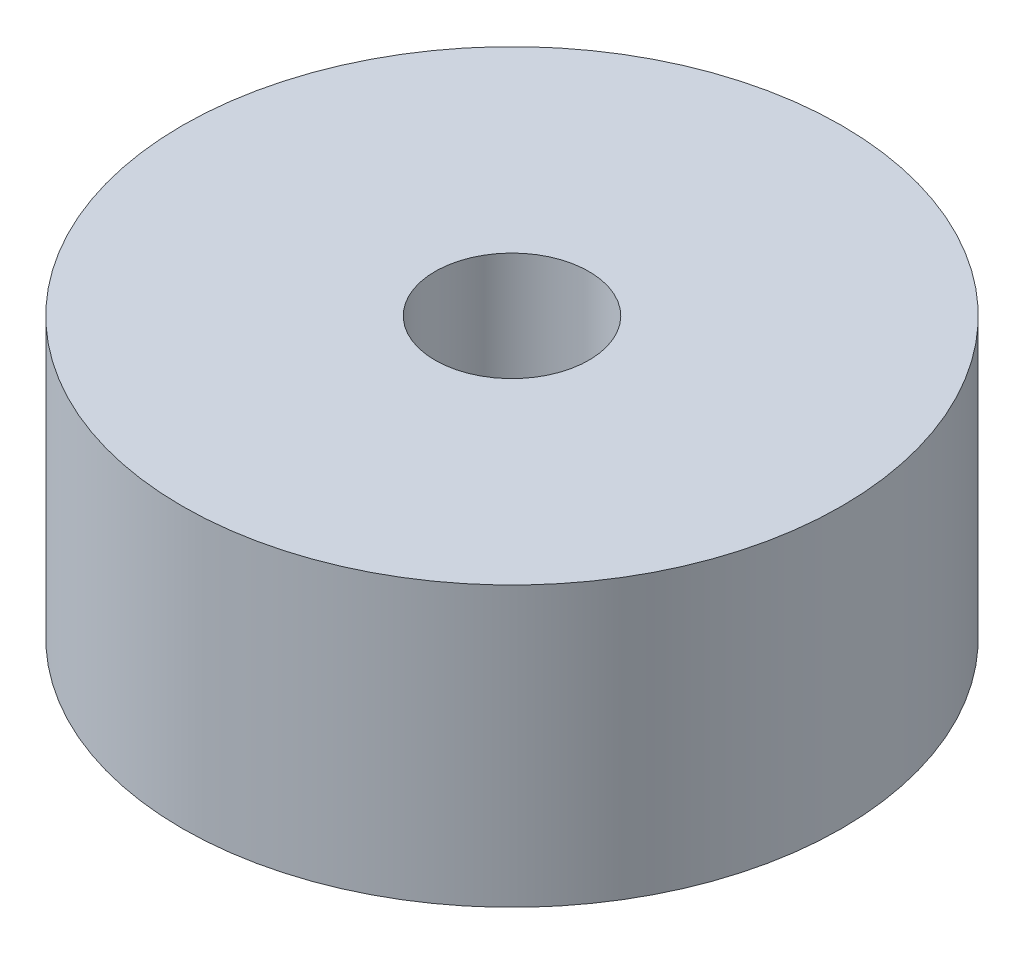
from build123d import *

# Parameters (mm, degrees)
SKETCH1_R           = 7.5
BOSS_EXTRUDE1_DEPTH = 6.35
SKETCH2_R           = 1.75
CUT_EXTRUDE1_DEPTH  = 7.35


with BuildPart() as part:
    # Sketch1 → Boss-Extrude1 (new body)
    with BuildSketch(Plane(origin=(0, 0, 0), x_dir=(1, 0, 0), z_dir=(0, 1, 0))):
        Circle(SKETCH1_R)
    extrude(amount=BOSS_EXTRUDE1_DEPTH)

    # Sketch2 → Cut-Extrude1 (cut, through all)
    with BuildSketch(Plane(origin=(0, 6.35, 0), x_dir=(1, 0, 0), z_dir=(0, 1, 0))):
        Circle(SKETCH2_R)
    extrude(amount=-CUT_EXTRUDE1_DEPTH, mode=Mode.SUBTRACT)


solid = part.part
